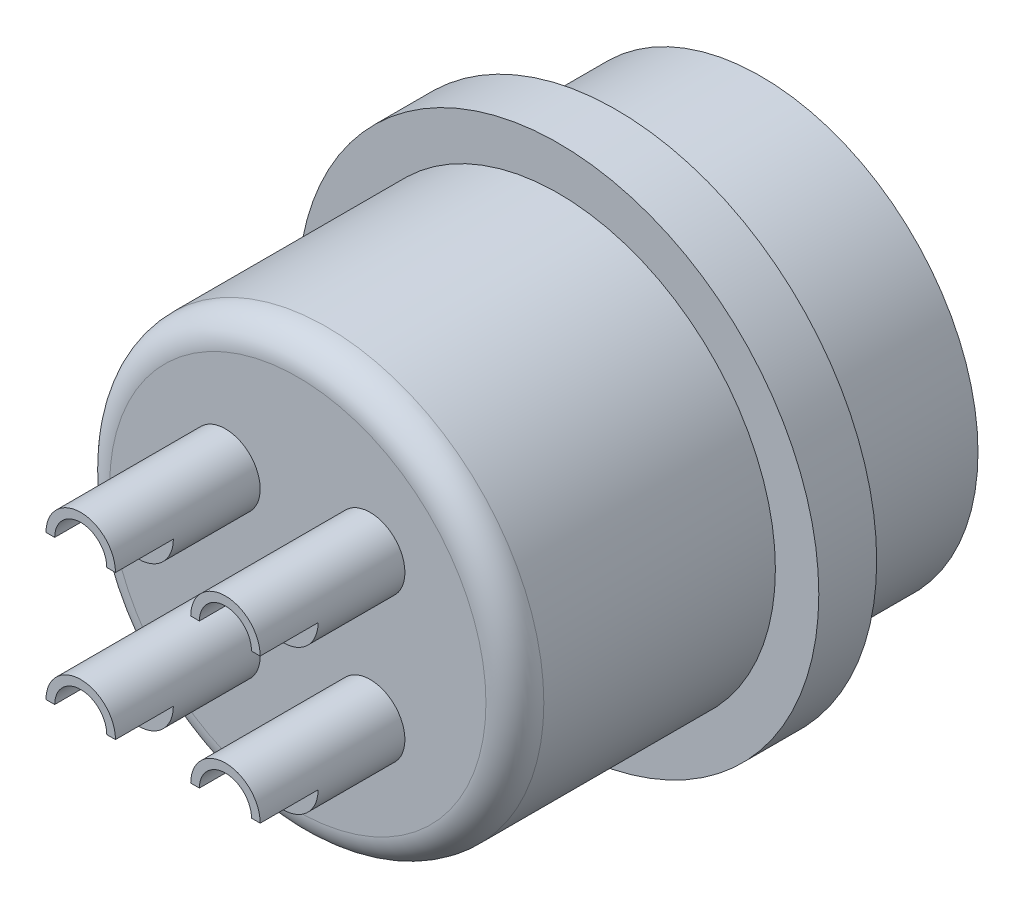
from build123d import *

# Parameters (mm, degrees)
SKETCH_1_R           = 7.5
EXTRUDE_1_DEPTH      = 5
SKETCH_2_R           = 9
EXTRUDE_2_DEPTH      = 2
SKETCH_3_R           = 7.5
EXTRUDE_3_DEPTH      = 9
CUT_EXTRUDE_1_DEPTH  = 10
EXTRUDE_4_DEPTH      = 5
EXTRUDE_4_DEPTH_BACK = 14
SKETCH_4_R           = 1.2
CUT_EXTRUDE_2_DEPTH  = 2
FILLET_1_R           = 1
FILLET_2_R           = 1


with BuildPart() as part:
    # Эскиз1 → Бобышка-Вытянуть1 (new body)
    with BuildSketch(Plane.XY):
        Circle(SKETCH_1_R)
    extrude(amount=EXTRUDE_1_DEPTH)

    # Эскиз2 → Бобышка-Вытянуть2 (add)
    with BuildSketch(Plane.XY.offset(5)):
        Circle(SKETCH_2_R)
    extrude(amount=EXTRUDE_2_DEPTH)

    # Эскиз3 → Бобышка-Вытянуть3 (add)
    with BuildSketch(Plane.XY.offset(7)):
        Circle(SKETCH_3_R)
    extrude(amount=EXTRUDE_3_DEPTH)

    # Эскиз5 → Вырез-Вытянуть1 (cut)
    with BuildSketch(Plane(origin=(0, 0, 0), x_dir=(-1, 0, 0), z_dir=(0, 0, -1))):
        with BuildLine():
            ThreePointArc((0.997037031, -6.423076923), (0, 6.5), (-0.997037031, -6.423076923))
            ThreePointArc((-0.997037031, -6.423076923), (0, -5.5), (0.997037031, -6.423076923))
        make_face()
    extrude(amount=-CUT_EXTRUDE_1_DEPTH, mode=Mode.SUBTRACT)

    # Эскиз4 → Бобышка-Вытянуть4 (add, two sides: drawn at the far end of the back side and taken through both)
    with BuildSketch(Plane.XY.offset(16).offset(-EXTRUDE_4_DEPTH_BACK)):
        with Locations((-2.5, 2.5)):
            Circle(SKETCH_4_R)
        with Locations((-2.5, -2.5)):
            Circle(SKETCH_4_R)
        with Locations((2.5, -2.5)):
            Circle(SKETCH_4_R)
        with Locations((2.5, 2.5)):
            Circle(SKETCH_4_R)
    extrude(amount=EXTRUDE_4_DEPTH + EXTRUDE_4_DEPTH_BACK)

    # Эскиз6 → Вырез-Вытянуть2 (cut)
    with BuildSketch(Plane.XY.offset(21)):
        with BuildLine():
            Line((-4.065638272, 2.5), (-3.4, 2.5))
            ThreePointArc((-3.4, 2.5), (-2.5, 3.4), (-1.6, 2.5))
            Line((-1.6, 2.5), (-1.02269763, 2.5))
            Line((-1.02269763, 2.5), (-1.813265542, 1.11023828))
            Line((-1.813265542, 1.11023828), (-3.304903111, 1.11023828))
            Line((-3.304903111, 1.11023828), (-4.065638272, 2.5))
        make_face()
        with BuildLine():
            Line((1.6, 2.5), (1.02269763, 2.5))
            Line((1.02269763, 2.5), (1.813265542, 1.11023828))
            Line((1.813265542, 1.11023828), (3.304903111, 1.11023828))
            Line((3.304903111, 1.11023828), (4.065638272, 2.5))
            Line((4.065638272, 2.5), (3.4, 2.5))
            ThreePointArc((3.4, 2.5), (2.5, 3.4), (1.6, 2.5))
        make_face()
        with BuildLine():
            Line((4.065638272, -2.5), (3.4, -2.5))
            ThreePointArc((3.4, -2.5), (2.5, -1.6), (1.6, -2.5))
            Line((1.6, -2.5), (1.02269763, -2.5))
            Line((1.02269763, -2.5), (1.813265542, -3.88976172))
            Line((1.813265542, -3.88976172), (3.304903111, -3.88976172))
            Line((3.304903111, -3.88976172), (4.065638272, -2.5))
        make_face()
        with BuildLine():
            Line((-1.02269763, -2.5), (-1.813265542, -3.88976172))
            Line((-1.813265542, -3.88976172), (-3.304903111, -3.88976172))
            Line((-3.304903111, -3.88976172), (-4.065638272, -2.5))
            Line((-4.065638272, -2.5), (-3.4, -2.5))
            ThreePointArc((-3.4, -2.5), (-2.5, -1.6), (-1.6, -2.5))
            Line((-1.6, -2.5), (-1.02269763, -2.5))
        make_face()
    extrude(amount=-CUT_EXTRUDE_2_DEPTH, mode=Mode.SUBTRACT)

    # Скругление1
    fillet_1_edges = [part.edges().sort_by_distance(p)[0] for p in [
        (1.3, -2.5, 2),
        (-3.7, -2.5, 2),
        (-3.7, 2.5, 2),
        (1.3, 2.5, 2),
    ]]
    fillet(fillet_1_edges, radius=FILLET_1_R)

    # Скругление2
    fillet_2_edges = [part.edges().sort_by_distance(p)[0] for p in [
        (-7.5, 0, 16),
    ]]
    fillet(fillet_2_edges, radius=FILLET_2_R)


solid = part.part
